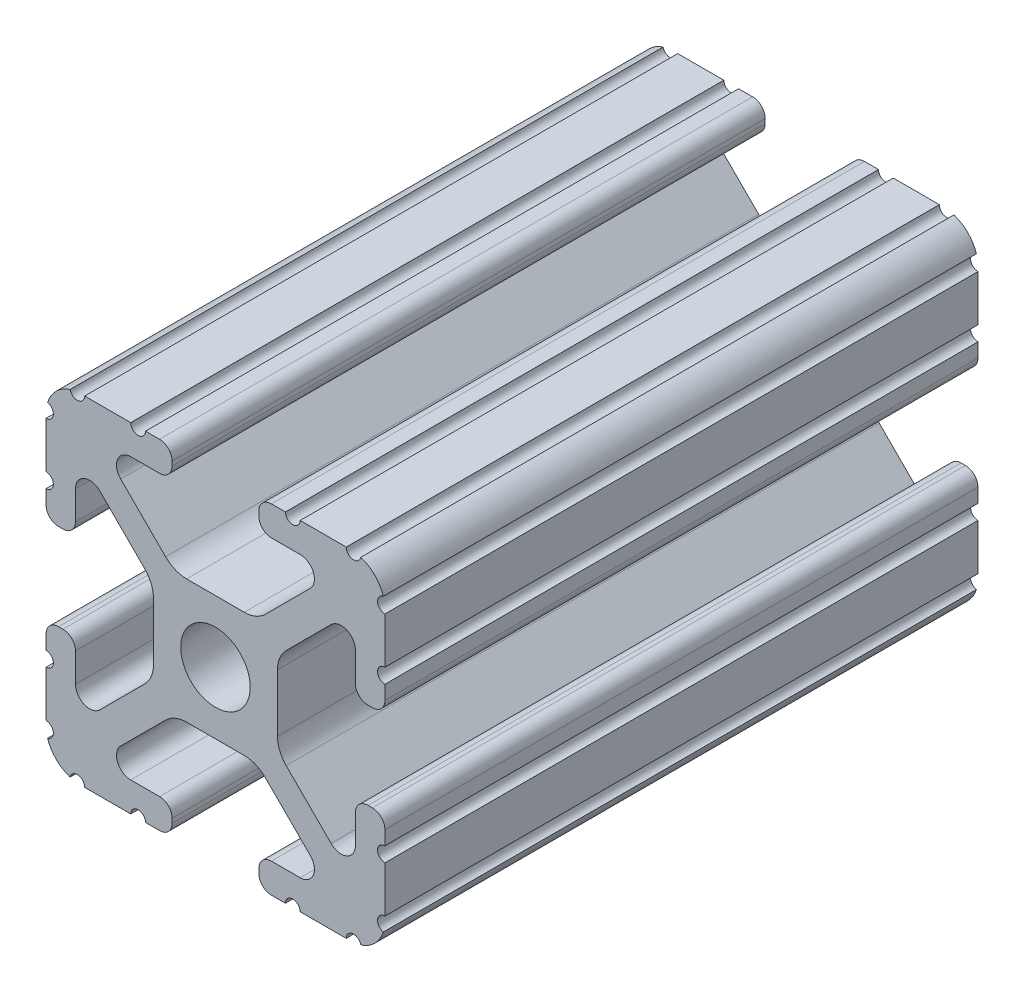
from build123d import *

# Parameters (mm, degrees)
BOSS_EXTRUDE1_DEPTH     = 22.225
SKETCH5_R               = 0.55245
CUT_EXTRUDE1_DEPTH      = 23.225
CUT_EXTRUDE1_DEPTH_BACK = 23.225
SKETCH6_R               = 2.555
CUT_EXTRUDE2_DEPTH      = 13.7
CUT_EXTRUDE2_DEPTH_BACK = 13.7
SKETCH7_R               = 2.54
CUT_EXTRUDE3_DEPTH      = 13.7
CUT_EXTRUDE3_DEPTH_BACK = 13.7


with BuildPart() as part:
    # Sketch4 → Boss-Extrude1 (new body, symmetric)
    with BuildSketch(Plane.XY):
        with BuildLine():
            Line((4.190365, -12.7), (10.11729625, -12.7))
            ThreePointArc((10.11729625, -12.7), (11.943543585, -11.943543585), (12.7, -10.11729625))
            Line((12.7, -10.11729625), (12.7, -4.190365))
            ThreePointArc((12.7, -4.190365), (12.42492494, -3.52627506), (11.760835, -3.2512))
            Line((11.760835, -3.2512), (11.429365, -3.2512))
            ThreePointArc((11.429365, -3.2512), (10.76527506, -3.52627506), (10.4902, -4.190365))
            Line((10.4902, -4.190365), (10.4902, -6.348478019))
            ThreePointArc((10.4902, -6.348478019), (9.830707141, -7.335478831), (8.666460301, -7.103895736))
            Line((8.666460301, -7.103895736), (5.299899128, -3.737334563))
            ThreePointArc((5.299899128, -3.737334563), (4.817571085, -3.015479634), (4.6482, -2.16399369))
            Line((4.6482, -2.16399369), (4.6482, 0))
            Line((4.6482, 0), (2.6035, 0))
            ThreePointArc((2.6035, 0), (1.840952505, -1.840952505), (0, -2.6035))
            Line((0, -2.6035), (0, -4.6482))
            Line((0, -4.6482), (2.16399369, -4.6482))
            ThreePointArc((2.16399369, -4.6482), (3.015479634, -4.817571085), (3.737334563, -5.299899128))
            Line((3.737334563, -5.299899128), (7.103895736, -8.666460301))
            ThreePointArc((7.103895736, -8.666460301), (7.335478831, -9.830707141), (6.348478019, -10.4902))
            Line((6.348478019, -10.4902), (4.190365, -10.4902))
            ThreePointArc((4.190365, -10.4902), (3.52627506, -10.76527506), (3.2512, -11.429365))
            Line((3.2512, -11.429365), (3.2512, -11.760835))
            ThreePointArc((3.2512, -11.760835), (3.52627506, -12.42492494), (4.190365, -12.7))
        make_face()
    extrude(amount=BOSS_EXTRUDE1_DEPTH, both=True)

    # Sketch5 → Cut-Extrude1 (cut, two sides)
    with BuildSketch(Plane.XY) as cut_extrude1_sk:
        with Locations((10.356153152, -12.7)):
            Circle(SKETCH5_R)
        with Locations((5.796028019, -12.7)):
            Circle(SKETCH5_R)
        with Locations((12.7, -10.356153152)):
            Circle(SKETCH5_R)
        with Locations((12.7, -5.796028019)):
            Circle(SKETCH5_R)
    extrude(amount=CUT_EXTRUDE1_DEPTH, mode=Mode.SUBTRACT)
    extrude(cut_extrude1_sk.sketch, amount=-CUT_EXTRUDE1_DEPTH_BACK, mode=Mode.SUBTRACT)

    # Mirror1: part across plane


with BuildPart() as part_1:
    add(part.part)
    add(part.part.mirror(Plane(origin=(0, 0, 0), x_dir=(0, 0, 1), z_dir=(1, 0, 0))))

    # Mirror2: part across plane


with BuildPart() as part_2:
    add(part_1.part)
    add(part_1.part.mirror(Plane.ZX))

    # Sketch6 → Cut-Extrude2 (cut, two sides)
    with BuildSketch(Plane(origin=(0, 0, 0), x_dir=(1, 0, 0), z_dir=(0, 1, 0))) as cut_extrude2_sk:
        with Locations((0, -9.525)):
            Circle(SKETCH6_R)
        with Locations((0, 9.525)):
            Circle(SKETCH6_R)
    extrude(amount=CUT_EXTRUDE2_DEPTH, mode=Mode.SUBTRACT)
    extrude(cut_extrude2_sk.sketch, amount=-CUT_EXTRUDE2_DEPTH_BACK, mode=Mode.SUBTRACT)

    # Sketch7 → Cut-Extrude3 (cut, two sides)
    with BuildSketch(Plane(origin=(0, 0, 0), x_dir=(0, 0, -1), z_dir=(1, 0, 0))) as cut_extrude3_sk:
        with Locations((-3.175, 0)):
            Circle(SKETCH7_R)
        with Locations((3.175, 0)):
            Circle(SKETCH7_R)
    extrude(amount=CUT_EXTRUDE3_DEPTH, mode=Mode.SUBTRACT)
    extrude(cut_extrude3_sk.sketch, amount=-CUT_EXTRUDE3_DEPTH_BACK, mode=Mode.SUBTRACT)


solid = part_2.part
